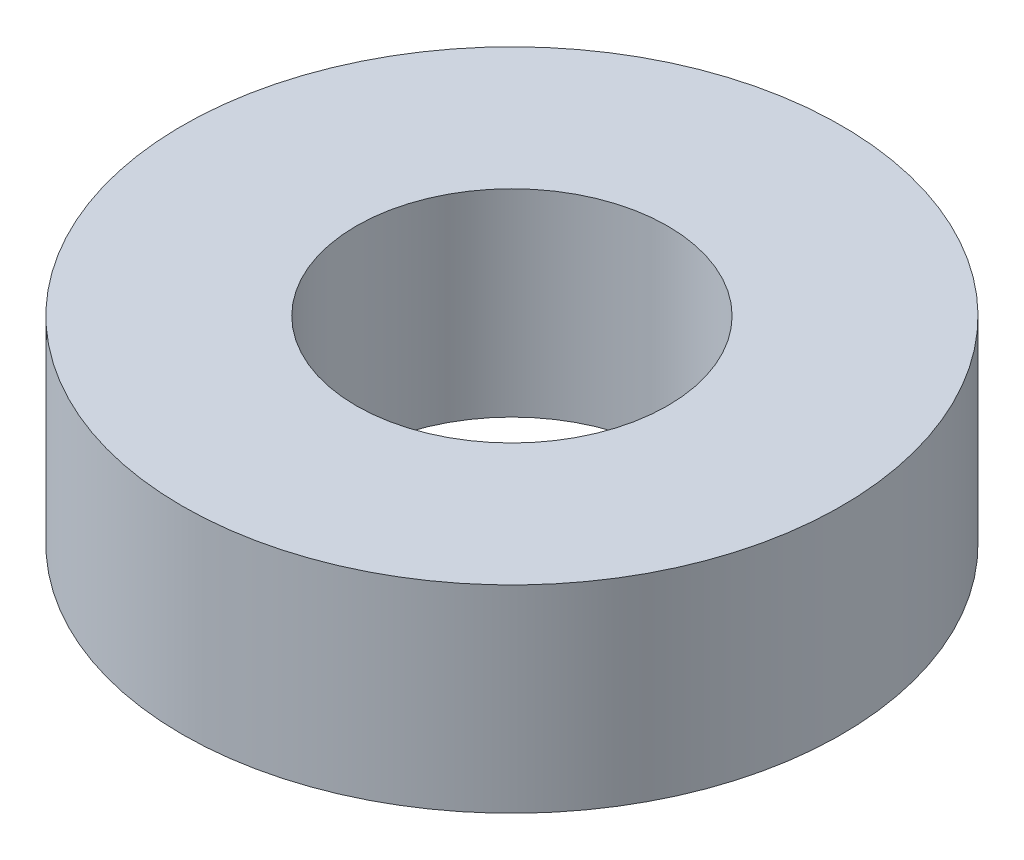
from build123d import *

# Parameters (mm, degrees)
SKETCH1_R           = 6.35
SKETCH1_R_2         = 3
BOSS_EXTRUDE1_DEPTH = 3.81


with BuildPart() as part:
    # Sketch1 → Boss-Extrude1 (new body)
    with BuildSketch(Plane(origin=(0, 0, 0), x_dir=(1, 0, 0), z_dir=(0, 1, 0))):
        Circle(SKETCH1_R)
        Circle(SKETCH1_R_2, mode=Mode.SUBTRACT)
    extrude(amount=BOSS_EXTRUDE1_DEPTH)


solid = part.part
